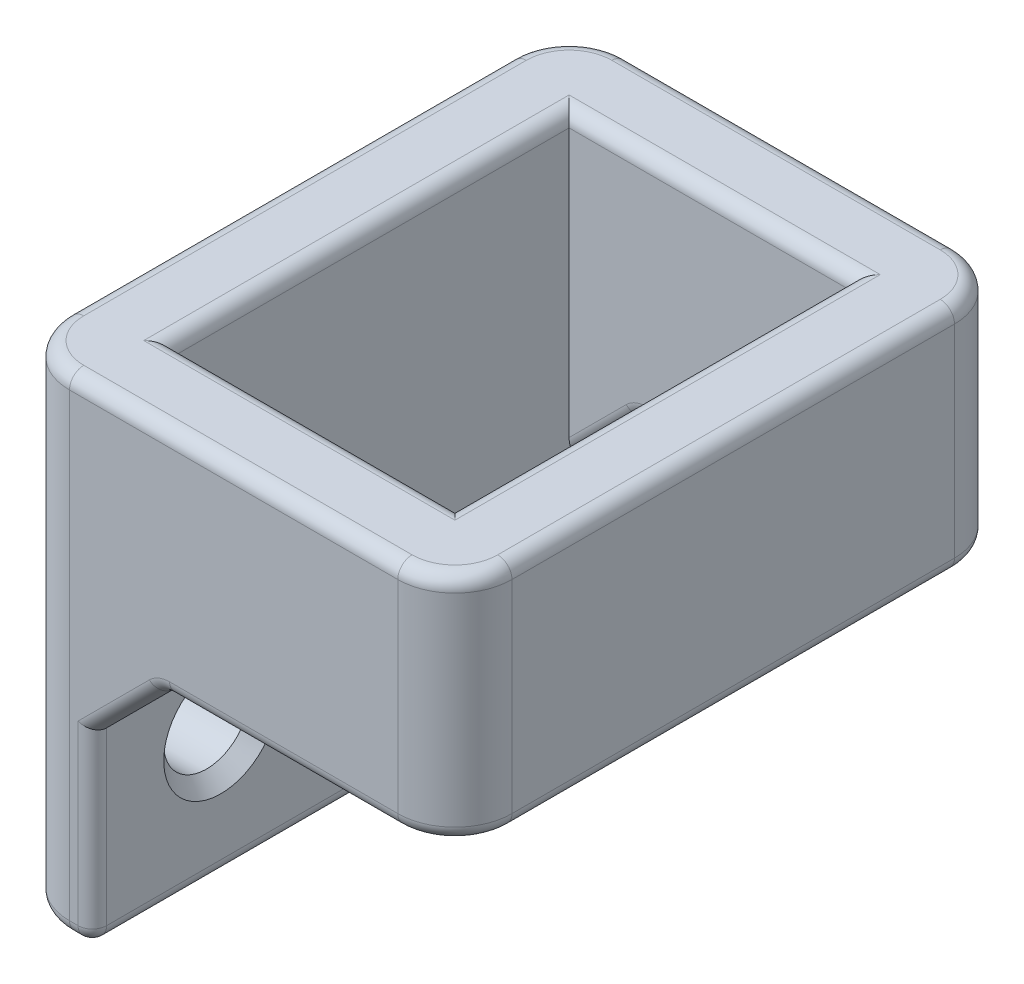
from build123d import *

# Parameters (mm, degrees)
SKETCH1_W           = 15.5
SKETCH1_H           = 19.5
SKETCH1_W_2         = 9.9
SKETCH1_H_2         = 13.9
BOSS_EXTRUDE1_DEPTH = 4.05
SKETCH2_W           = 19.5
SKETCH2_H           = 9
SKETCH2_R           = 1.5
BOSS_EXTRUDE2_DEPTH = 2.8
CHAMFER1_SIZE       = 2.5
FILLET1_R           = 2
FILLET2_R           = 0.5
CHAMFER2_SIZE       = 0.5


with BuildPart() as part:
    # Sketch1 → Boss-Extrude1 (new body, symmetric)
    with BuildSketch(Plane(origin=(0, 0, 0), x_dir=(1, 0, 0), z_dir=(0, 1, 0))):
        Rectangle(SKETCH1_W, SKETCH1_H)
        Rectangle(SKETCH1_W_2, SKETCH1_H_2, mode=Mode.SUBTRACT)
    extrude(amount=BOSS_EXTRUDE1_DEPTH, both=True)

    # Sketch2 → Boss-Extrude2 (add)
    with BuildSketch(Plane.ZY.offset(7.75)):
        with Locations((0, -8.55)):
            Rectangle(SKETCH2_W, SKETCH2_H)
        with Locations((-5.25, -8.55)):
            Circle(SKETCH2_R, mode=Mode.SUBTRACT)
        with Locations((5.25, -8.55)):
            Circle(SKETCH2_R, mode=Mode.SUBTRACT)
    extrude(amount=-BOSS_EXTRUDE2_DEPTH)

    # Chamfer1
    chamfer1_edges = [part.edges().sort_by_distance(p)[0] for p in [
        (-4.95, -4.05, -8.35),
        (-4.95, -4.05, 8.35),
    ]]
    chamfer(chamfer1_edges, length=CHAMFER1_SIZE)

    # Fillet1
    fillet1_edges = [part.edges().sort_by_distance(p)[0] for p in [
        (-7.75, -4.5, -9.75),
        (7.75, 0, -9.75),
        (7.75, 0, 9.75),
        (-7.75, -4.5, 9.75),
    ]]
    fillet(fillet1_edges, radius=FILLET1_R)

    # Fillet2
    fillet2_edges = [part.edges().sort_by_distance(p)[0] for p in [
        (4.95, -4.05, 0),
        (1.25, -4.05, -6.95),
        (-4.95, 4.05, 0),
        (0, 4.05, 6.95),
        (4.95, 4.05, 0),
        (0, 4.05, -6.95),
        (-5.35, -13.05, -9.75),
        (-4.95, -9.8, 9.75),
        (-4.95, -13.05, 0),
        (-5.35, -13.05, 9.75),
        (1.65, -4.05, 9.75),
        (1.25, -4.05, 6.95),
        (-2.45, -4.05, 8.35),
        (-2.45, -4.05, -8.35),
        (-4.95, -9.8, -9.75),
        (-3.7, -5.3, -9.75),
        (-3.7, -5.3, -6.95),
        (-3.7, -5.3, 6.95),
        (-3.7, -5.3, 9.75),
        (1.65, -4.05, -9.75),
        (0, 4.05, -9.75),
        (7.75, -4.05, 0),
        (7.164213562, -4.05, 9.164213562),
        (7.164213562, -4.05, -9.164213562),
        (7.75, 4.05, 0),
        (-7.75, 4.05, 0),
        (0, 4.05, 9.75),
        (-7.164213562, 4.05, 9.164213562),
        (-7.164213562, 4.05, -9.164213562),
        (7.164213562, 4.05, 9.164213562),
        (7.164213562, 4.05, -9.164213562),
        (-7.75, -13.05, 0),
        (-7.164213562, -13.05, 9.164213562),
        (-7.164213562, -13.05, -9.164213562),
    ]]
    fillet(fillet2_edges, radius=FILLET2_R)

    # Chamfer2
    chamfer2_edges = [part.edges().sort_by_distance(p)[0] for p in [
        (-4.95, -8.55, 3.75),
        (-4.95, -8.55, -6.75),
    ]]
    chamfer(chamfer2_edges, length=CHAMFER2_SIZE)


solid = part.part
